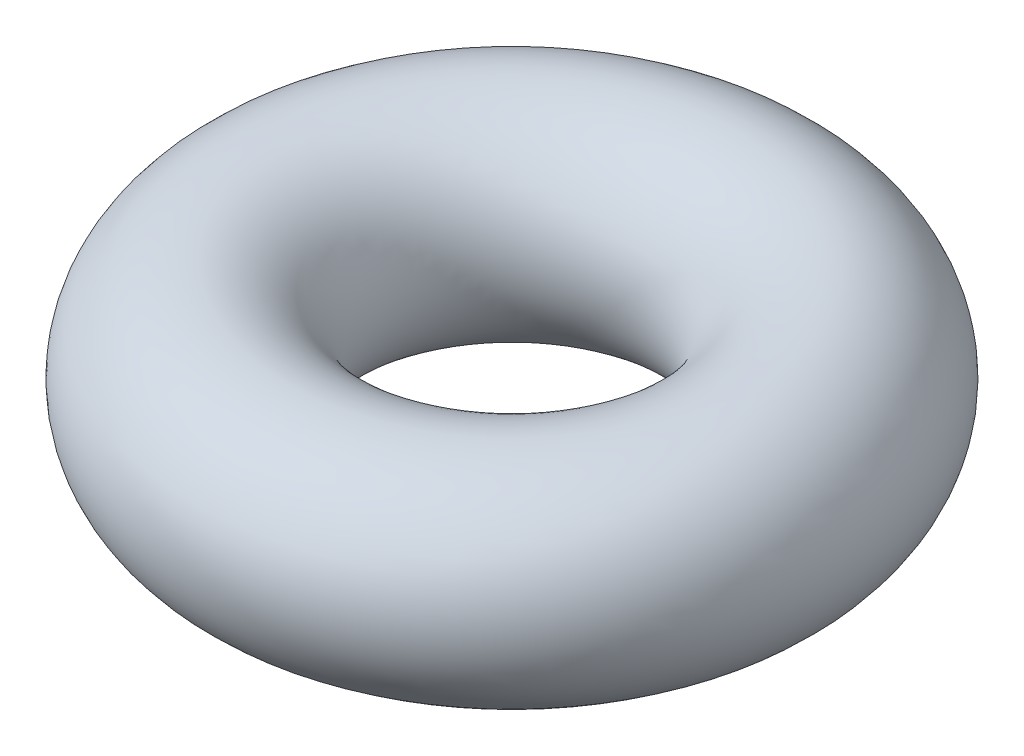
from build123d import *

# Parameters (mm, degrees)
ESQUISSE1_R = 0.9525


with BuildPart() as part:
    # Esquisse1 → Révolution1 (revolve)
    with BuildSketch(Plane.XY):
        with Locations((2.0475, 0)):
            Circle(ESQUISSE1_R)
    revolve(axis=Axis((0, -2.320303714, 0), (0, 1, 0)))


solid = part.part
